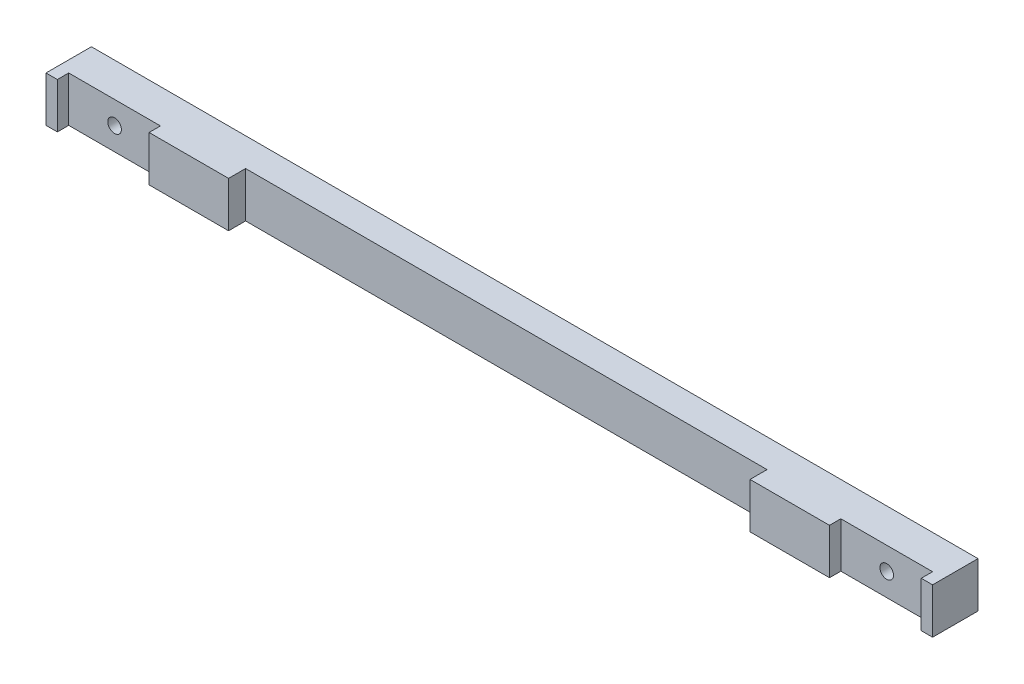
from build123d import *

# Parameters (mm, degrees)
SKETCH1_W           = 247.9294
SKETCH1_H           = 12.7
BOSS_EXTRUDE1_DEPTH = 12.7
SKETCH2_W           = 25.654
SKETCH2_H           = 21.428464986
CUT_EXTRUDE1_DEPTH  = 3.175
SKETCH3_W           = 145.8214
SKETCH3_H           = 22.473236176
CUT_EXTRUDE2_DEPTH  = 4.7625
CUT_EXTRUDE3_START  = -9.525
SKETCH4_R           = 1.905
CUT_EXTRUDE3_DEPTH  = 9.525


with BuildPart() as part:
    # Sketch1 → Boss-Extrude1 (new body)
    with BuildSketch(Plane.XY):
        Rectangle(SKETCH1_W, SKETCH1_H)
    extrude(amount=BOSS_EXTRUDE1_DEPTH)

    # Sketch2 → Cut-Extrude1 (cut)
    with BuildSketch(Plane.XY.offset(12.7)):
        with Locations((-107.9627, 0)):
            Rectangle(SKETCH2_W, SKETCH2_H)
        with Locations((107.9627, 0)):
            Rectangle(SKETCH2_W, SKETCH2_H)
    extrude(amount=-CUT_EXTRUDE1_DEPTH, mode=Mode.SUBTRACT)

    # Sketch3 → Cut-Extrude2 (cut)
    with BuildSketch(Plane.XY.offset(12.7)):
        Rectangle(SKETCH3_W, SKETCH3_H)
    extrude(amount=-CUT_EXTRUDE2_DEPTH, mode=Mode.SUBTRACT)

    # Sketch4 → Cut-Extrude3 (cut)
    with BuildSketch(Plane.XY.offset(9.525).offset(CUT_EXTRUDE3_START)):
        with Locations((-107.9627, 0)):
            Circle(SKETCH4_R)
        with Locations((107.9627, 0)):
            Circle(SKETCH4_R)
    extrude(amount=CUT_EXTRUDE3_DEPTH, mode=Mode.SUBTRACT)


solid = part.part
